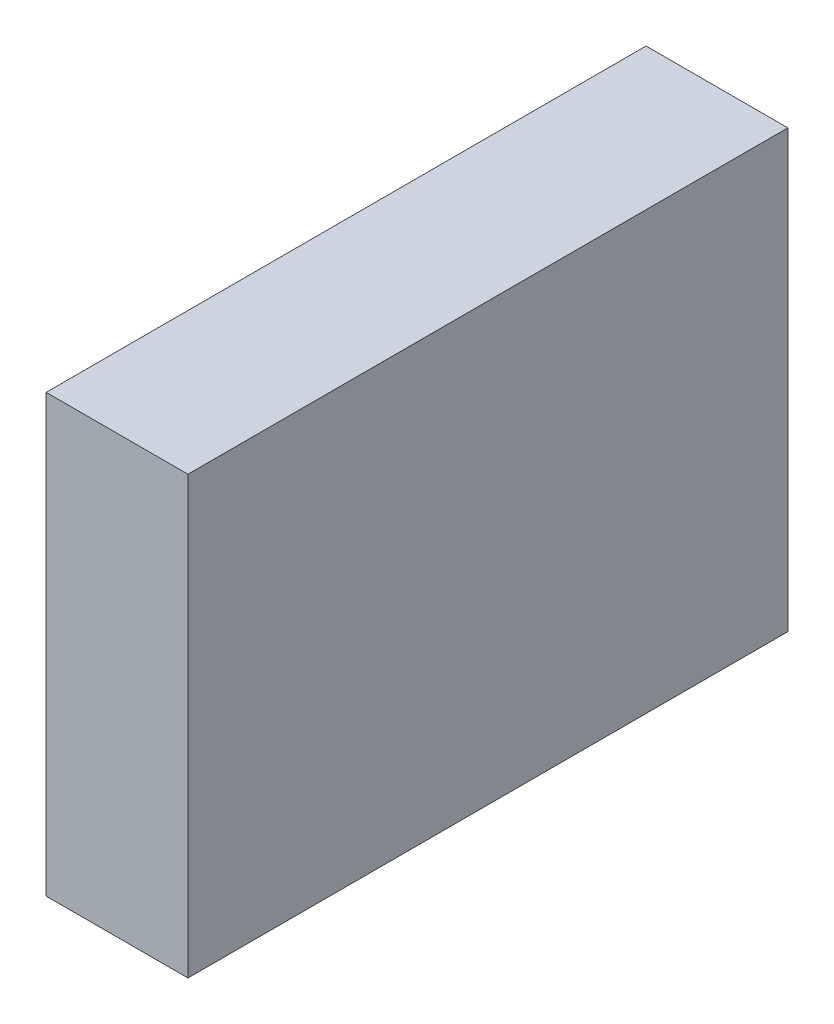
from build123d import *

# Parameters (mm, degrees)
SKETCH1_W           = 13
SKETCH1_H           = 40
BOSS_EXTRUDE1_DEPTH = 55


with BuildPart() as part:
    # Sketch1 → Boss-Extrude1 (new body)
    with BuildSketch(Plane.XY):
        with Locations((374.966548048, 258)):
            Rectangle(SKETCH1_W, SKETCH1_H)
    extrude(amount=BOSS_EXTRUDE1_DEPTH)


solid = part.part
